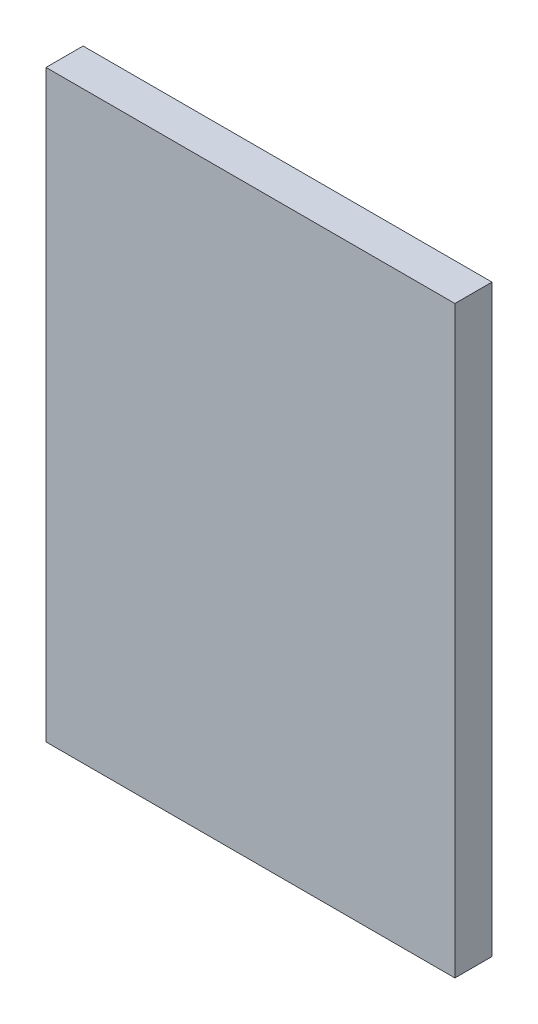
from build123d import *

# Parameters (mm, degrees)
SKETCH1_W           = 35
SKETCH1_H           = 50
BOSS_EXTRUDE1_DEPTH = 3.175


with BuildPart() as part:
    # Sketch1 → Boss-Extrude1 (new body)
    with BuildSketch(Plane.XY):
        Rectangle(SKETCH1_W, SKETCH1_H)
    extrude(amount=BOSS_EXTRUDE1_DEPTH)


solid = part.part
